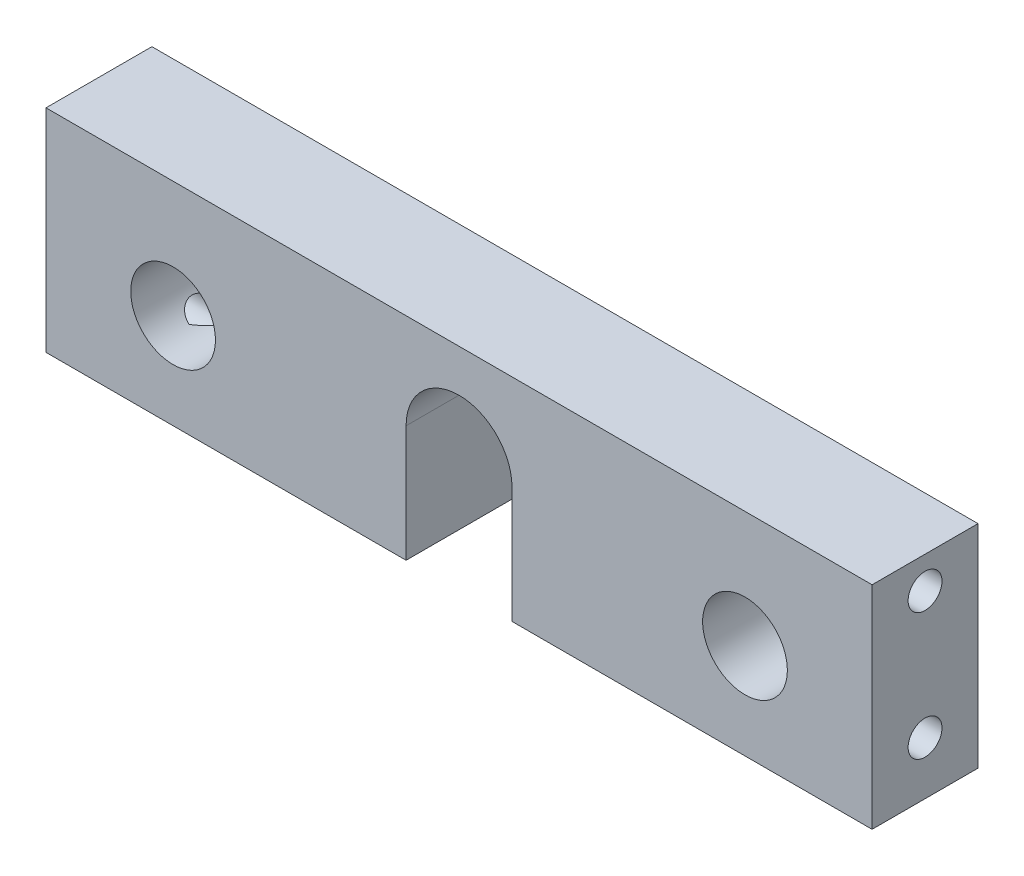
from build123d import *

# Parameters (mm, degrees)
SKETCH1_W                       = 5
SKETCH1_H                       = 10
BOSS_EXTRUDE1_DEPTH             = 39
TAP_DRILL_FOR_M2X0_4_TAP1_D     = 1.6
TAP_DRILL_FOR_M2X0_4_TAP1_DEPTH = 5
TAP_DRILL_FOR_M2X0_4_TAP1_TIP   = 0.480688495
TAP_DRILL_FOR_M2X0_4_TAP2_D     = 1.6
TAP_DRILL_FOR_M2X0_4_TAP2_DEPTH = 5
TAP_DRILL_FOR_M2X0_4_TAP2_TIP   = 0.480688495
CUT_EXTRUDE1_REACH              = 7
SKETCH8_R                       = 2


with BuildPart() as part:
    # Sketch1 → Boss-Extrude1 (new body)
    with BuildSketch(Plane(origin=(0, 0, 0), x_dir=(0, 0, -1), z_dir=(1, 0, 0))):
        with Locations((0, 5)):
            Rectangle(SKETCH1_W, SKETCH1_H)
    extrude(amount=BOSS_EXTRUDE1_DEPTH)

    # Tap Drill for M2x0.4 Tap1
    with Locations(Plane(origin=(39, 0, 0), x_dir=(0, 0, -1), z_dir=(1, 0, 0))):
        with Locations((0, 8.5), (0, 2.5)):
            Hole(TAP_DRILL_FOR_M2X0_4_TAP1_D / 2, depth=TAP_DRILL_FOR_M2X0_4_TAP1_DEPTH)
            with Locations((0, 0, -(TAP_DRILL_FOR_M2X0_4_TAP1_DEPTH + TAP_DRILL_FOR_M2X0_4_TAP1_TIP / 2))):  # 118° drill point
                Cone(0, TAP_DRILL_FOR_M2X0_4_TAP1_D / 2, TAP_DRILL_FOR_M2X0_4_TAP1_TIP, mode=Mode.SUBTRACT)

    # Tap Drill for M2x0.4 Tap2
    with Locations(Plane.ZY):
        with Locations((0, 8.5), (0, 2.5)):
            Hole(TAP_DRILL_FOR_M2X0_4_TAP2_D / 2, depth=TAP_DRILL_FOR_M2X0_4_TAP2_DEPTH)
            with Locations((0, 0, -(TAP_DRILL_FOR_M2X0_4_TAP2_DEPTH + TAP_DRILL_FOR_M2X0_4_TAP2_TIP / 2))):  # 118° drill point
                Cone(0, TAP_DRILL_FOR_M2X0_4_TAP2_D / 2, TAP_DRILL_FOR_M2X0_4_TAP2_TIP, mode=Mode.SUBTRACT)

    # Sketch8 → Cut-Extrude1 (cut, up to next)
    with BuildSketch(Plane.XY.offset(2.5), mode=Mode.PRIVATE) as cut_extrude1_sk1:
        with Locations((6, 4.5)):
            Circle(SKETCH8_R)
    cut_extrude1_tool1 = extrude(cut_extrude1_sk1.sketch, amount=-CUT_EXTRUDE1_REACH, mode=Mode.PRIVATE) & part.part
    add(cut_extrude1_tool1.solids().sort_by_distance((6, 4.5, 2.5))[0], mode=Mode.SUBTRACT)
    # Sketch8 → Cut-Extrude1 (cut, up to next)
    with BuildSketch(Plane.XY.offset(2.5), mode=Mode.PRIVATE) as cut_extrude1_sk2:
        with Locations((33, 4.5)):
            Circle(SKETCH8_R)
    cut_extrude1_tool2 = extrude(cut_extrude1_sk2.sketch, amount=-CUT_EXTRUDE1_REACH, mode=Mode.PRIVATE) & part.part
    add(cut_extrude1_tool2.solids().sort_by_distance((33, 4.5, 2.5))[0], mode=Mode.SUBTRACT)
    # Sketch8 → Cut-Extrude1 (cut, up to next)
    with BuildSketch(Plane.XY.offset(2.5), mode=Mode.PRIVATE) as cut_extrude1_sk3:
        with BuildLine():
            Line((17, 0), (17, 5.5))
            ThreePointArc((17, 5.5), (19.5, 8), (22, 5.5))
            Line((22, 5.5), (22, 0))
            Line((22, 0), (17, 0))
        make_face()
    cut_extrude1_tool3 = extrude(cut_extrude1_sk3.sketch, amount=-CUT_EXTRUDE1_REACH, mode=Mode.PRIVATE) & part.part
    add(cut_extrude1_tool3.solids().sort_by_distance((19.5, 3.752606, 2.5))[0], mode=Mode.SUBTRACT)


solid = part.part
